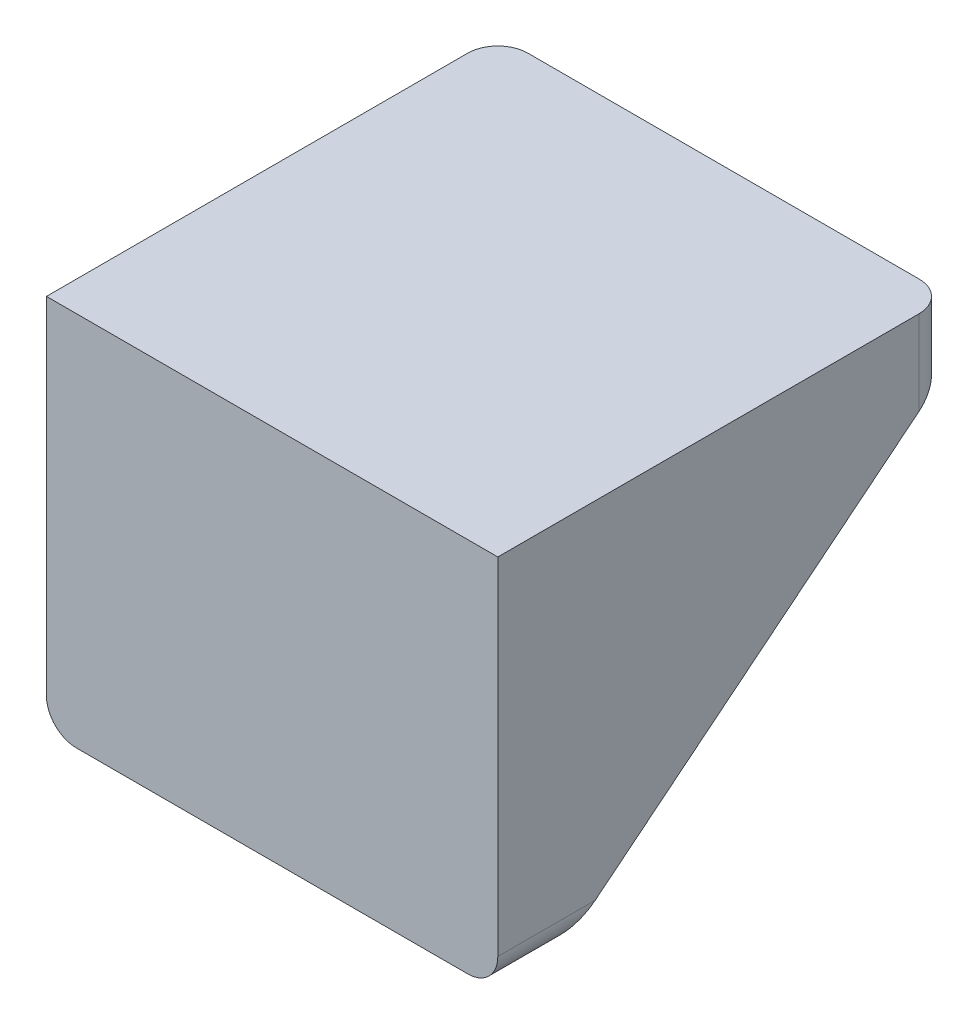
from build123d import *

# Parameters (mm, degrees)
BOSS_EXTRUDE1_DEPTH = 15
BOSS_EXTRUDE2_DEPTH = 4
FILLET1_R           = 2


with BuildPart() as part:
    # Sketch1 → Boss-Extrude1 (new body, symmetric)
    with BuildSketch(Plane(origin=(0, 0, 0), x_dir=(0, 0, -1), z_dir=(1, 0, 0))):
        Polygon((0, -12.5), (0, 12.5), (30, 12.5), (30, 8.5), (4, 8.5), (4, -12.5), align=None)
    extrude(amount=BOSS_EXTRUDE1_DEPTH, both=True)

    # Sketch2 → Boss-Extrude2 (add)
    with BuildSketch(Plane(origin=(15, 0, 0), x_dir=(0, 0, -1), z_dir=(1, 0, 0))):
        Polygon((30, 8.5), (4, -12.5), (4, 8.5), align=None)
    boss_extrude2 = extrude(amount=-BOSS_EXTRUDE2_DEPTH)

    # Mirror1: Boss-Extrude2 across plane
    add(boss_extrude2.mirror(Plane(origin=(0, 0, 0), x_dir=(0, 0, 1), z_dir=(1, 0, 0))))

    # Fillet1
    fillet1_edges = [part.edges().sort_by_distance(p)[0] for p in [
        (15, -12.5, -2),
        (15, 10.5, -30),
        (-15, -12.5, -2),
        (-15, 10.5, -30),
    ]]
    fillet(fillet1_edges, radius=FILLET1_R)


solid = part.part
